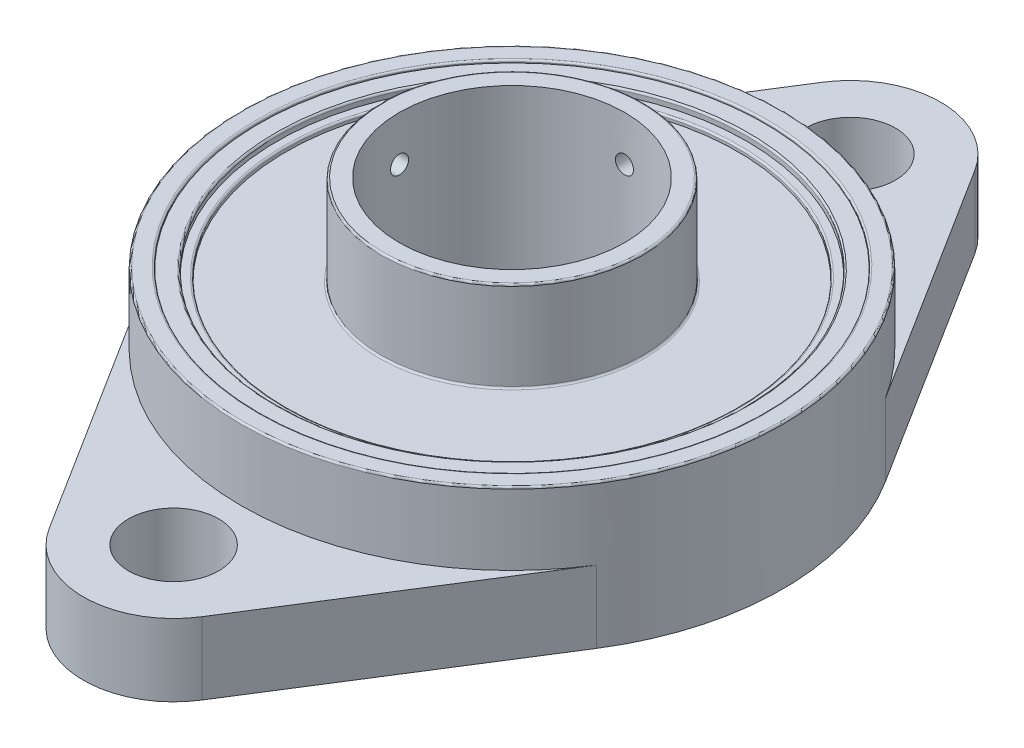
from build123d import *

# Parameters (mm, degrees)
SKETCH1_R             = 4.999999999999999
SKETCH1_R_2           = 27.999999999999996
EXTRUDE_A1_DEPTH      = 8
SKETCH1_3_R           = 27.999999999999996
EXTRUDE_A_DEPTH       = 16
SKETCH1_4_R           = 14.5
SKETCH1_4_R_2         = 12.5
EXTRUDE_A0_DEPTH      = 24.5
BEARING_START         = 2
SKETCH1_7_R           = 25.999999999999996
SKETCH1_7_R_2         = 24.999999999999993
BEARING_OUTER_D_DEPTH = 13
BOSS_EXTRUDE6_START   = 1.2
SKETCH1_8_R           = 27.999999999999996
SKETCH1_8_R_2         = 25.999999999999996
BOSS_EXTRUDE6_DEPTH   = 14.5
BOSS_EXTRUDE7_START   = 1.5
SKETCH1_9_R           = 24.999999999999993
SKETCH1_9_R_2         = 14.5
BOSS_EXTRUDE7_DEPTH   = 13
CUT_EXTRUDE1_REACH    = 63.29
SKETCH2_R             = 1.0000000000000018
CUT_EXTRUDE2_REACH    = 63.29
SKETCH3_R             = 1.0000000000000024
FILLET1_R             = 0.2
FILLET2_R             = 0.2


with BuildPart() as part:
    # Sketch1 → Extrude A1 (new body)
    with BuildSketch(Plane(origin=(0, 0, 0), x_dir=(1, 0, 0), z_dir=(0, 1, 0))):
        with BuildLine():
            Line((8.459051693633015, -42.833333333333336), (25.37715508089905, -16))
            ThreePointArc((25.377155080899044, -15.999999999999996), (30, 0), (25.377155080899044, 15.999999999999993))
            Line((25.37715508089905, 16), (8.459051693633015, 42.833333333333336))
            ThreePointArc((8.459051693633013, 42.833333333333336), (1.33e-15, 47.5), (-8.459051693633013, 42.833333333333336))
            Line((-8.459051693633015, 42.833333333333336), (-25.37715508089905, 16))
            ThreePointArc((-25.377155080899048, 15.99999999999999), (-30, 3.67e-15), (-25.37715508089905, -15.999999999999982))
            Line((-25.37715508089905, -16), (-8.459051693633015, -42.833333333333336))
            ThreePointArc((-8.459051693633013, -42.833333333333336), (-8.9e-16, -47.5), (8.459051693633013, -42.833333333333336))
        make_face()
        with Locations((0, -37.5)):
            Circle(SKETCH1_R, mode=Mode.SUBTRACT)
        Circle(SKETCH1_R_2, mode=Mode.SUBTRACT)
        with Locations((0, 37.5)):
            Circle(SKETCH1_R, mode=Mode.SUBTRACT)
    extrude(amount=EXTRUDE_A1_DEPTH)

    # Sketch1_3 → Extrude A (add)
    with BuildSketch(Plane(origin=(0, 0, 0), x_dir=(1, 0, 0), z_dir=(0, 1, 0))):
        with BuildLine():
            ThreePointArc((-25.37715508089905, -15.999999999999982), (-5.51e-15, -30), (25.377155080899044, -15.999999999999993))
            ThreePointArc((25.377155080899044, -15.999999999999993), (28.82112638696631, -8.32722485504711), (30, -7.35e-15))
            ThreePointArc((30, 0), (28.82112638696631, 8.327224855047108), (25.377155080899044, 15.999999999999993))
            ThreePointArc((25.377155080899044, 15.999999999999993), (-4.82e-15, 30), (-25.377155080899048, 15.99999999999999))
            ThreePointArc((-25.377155080899048, 15.99999999999999), (-30, 3.67e-15), (-25.37715508089905, -15.999999999999982))
        make_face()
        Circle(SKETCH1_3_R, mode=Mode.SUBTRACT)
    extrude(amount=EXTRUDE_A_DEPTH)



with BuildPart() as body_2:
    # Sketch1_4 → Extrude A0 (new body)
    with BuildSketch(Plane(origin=(0, 0, 0), x_dir=(1, 0, 0), z_dir=(0, 1, 0))):
        Circle(SKETCH1_4_R)
        Circle(SKETCH1_4_R_2, mode=Mode.SUBTRACT)
    extrude(amount=EXTRUDE_A0_DEPTH)


with BuildPart() as body_3:
    # Sketch1_7 → Bearing outer d (new body)
    with BuildSketch(Plane(origin=(0, 0, 0), x_dir=(1, 0, 0), z_dir=(0, 1, 0)).offset(BEARING_START)):
        Circle(SKETCH1_7_R)
        Circle(SKETCH1_7_R_2, mode=Mode.SUBTRACT)
    extrude(amount=BEARING_OUTER_D_DEPTH)


with BuildPart() as part_1:
    add(part.part)

    add(body_3.part)  # Boss-Extrude6 merges body 3
    # Sketch1_8 → Boss-Extrude6 (add)
    with BuildSketch(Plane(origin=(0, 0, 0), x_dir=(1, 0, 0), z_dir=(0, 1, 0)).offset(BOSS_EXTRUDE6_START)):
        Circle(SKETCH1_8_R)
        Circle(SKETCH1_8_R_2, mode=Mode.SUBTRACT)
    extrude(amount=BOSS_EXTRUDE6_DEPTH)


    add(body_2.part)  # Boss-Extrude7 merges body 2
    # Sketch1_9 → Boss-Extrude7 (add)
    with BuildSketch(Plane(origin=(0, 0, 0), x_dir=(1, 0, 0), z_dir=(0, 1, 0)).offset(BOSS_EXTRUDE7_START)):
        Circle(SKETCH1_9_R)
        Circle(SKETCH1_9_R_2, mode=Mode.SUBTRACT)
    extrude(amount=BOSS_EXTRUDE7_DEPTH)

    # Sketch2 → Cut-Extrude1 (cut, up to next)
    with BuildSketch(Plane(origin=(0, 0, 0), x_dir=(0, 0, -1), z_dir=(1, 0, 0)), mode=Mode.PRIVATE) as cut_extrude1_sk1:
        with Locations((-8.7e-16, 19.5)):
            Circle(SKETCH2_R)
    cut_extrude1_tool1 = extrude(cut_extrude1_sk1.sketch, amount=-CUT_EXTRUDE1_REACH, mode=Mode.PRIVATE) & part_1.part
    add(cut_extrude1_tool1.solids().sort_by_distance((0, 19.5, 0))[0], mode=Mode.SUBTRACT)

    # Sketch3 → Cut-Extrude2 (cut, up to next)
    with BuildSketch(Plane.XY, mode=Mode.PRIVATE) as cut_extrude2_sk1:
        with Locations((0, 19.5)):
            Circle(SKETCH3_R)
    cut_extrude2_tool1 = extrude(cut_extrude2_sk1.sketch, amount=-CUT_EXTRUDE2_REACH, mode=Mode.PRIVATE) & part_1.part
    add(cut_extrude2_tool1.solids().sort_by_distance((0, 19.5, 0))[0], mode=Mode.SUBTRACT)

    # Fillet1
    fillet1_edges = [part_1.edges().sort_by_distance(p)[0] for p in [
        (-24.999999999999993, 15, -3.06e-15),
    ]]
    fillet(fillet1_edges, radius=FILLET1_R)

    # Fillet2
    fillet2_edges = [part_1.edges().sort_by_distance(p)[0] for p in [
        (-14.5, 24.5, -1.78e-15),
        (-14.5, 14.5, -1.78e-15),
        (-29.99999999999998, 16, -9.2e-15),
        (-27.999999999999996, 16, -3.43e-15),
        (-25.999999999999996, 15.7, -3.18e-15),
    ]]
    fillet(fillet2_edges, radius=FILLET2_R)


solid = part_1.part
